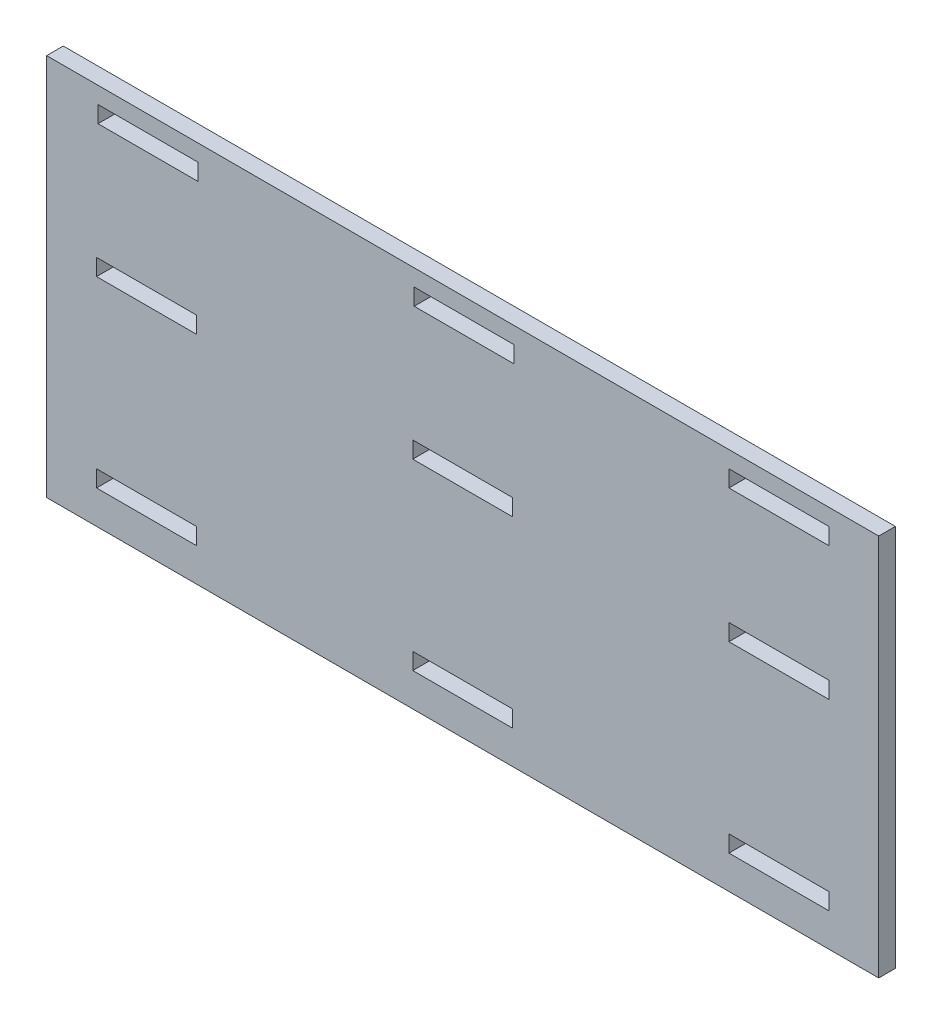
from build123d import *

# Parameters (mm, degrees)
SKETCH2_W           = 250
SKETCH2_H           = 115
SKETCH2_W_2         = 30
SKETCH2_H_2         = 5
BOSS_EXTRUDE1_DEPTH = 5


with BuildPart() as part:
    # Sketch2 → Boss-Extrude1 (new body)
    with BuildSketch(Plane.XY):
        Rectangle(SKETCH2_W, SKETCH2_H)
        with Locations((-94.565217391, 50)):
            Rectangle(SKETCH2_W_2, SKETCH2_H_2, mode=Mode.SUBTRACT)
        with Locations((0.434782609, 50)):
            Rectangle(SKETCH2_W_2, SKETCH2_H_2, mode=Mode.SUBTRACT)
        with Locations((95, 50)):
            Rectangle(SKETCH2_W_2, SKETCH2_H_2, mode=Mode.SUBTRACT)
        with Locations((95, 10)):
            Rectangle(SKETCH2_W_2, SKETCH2_H_2, mode=Mode.SUBTRACT)
        with Locations((0, 10)):
            Rectangle(SKETCH2_W_2, SKETCH2_H_2, mode=Mode.SUBTRACT)
        with Locations((-95, 10)):
            Rectangle(SKETCH2_W_2, SKETCH2_H_2, mode=Mode.SUBTRACT)
        with Locations((-95, -45)):
            Rectangle(SKETCH2_W_2, SKETCH2_H_2, mode=Mode.SUBTRACT)
        with Locations((0, -45)):
            Rectangle(SKETCH2_W_2, SKETCH2_H_2, mode=Mode.SUBTRACT)
        with Locations((95, -45)):
            Rectangle(SKETCH2_W_2, SKETCH2_H_2, mode=Mode.SUBTRACT)
    extrude(amount=BOSS_EXTRUDE1_DEPTH)


solid = part.part
